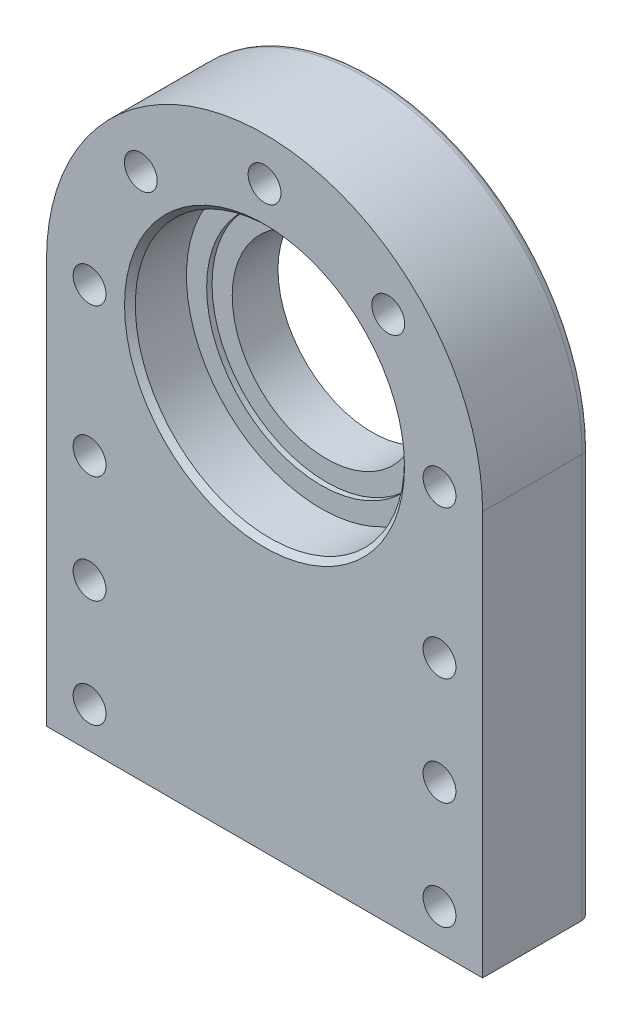
from build123d import *

# Parameters (mm, degrees)
BOSS_EXTRUDE1_DEPTH = 40
SKETCH2_R           = 6.1
CUT_EXTRUDE1_DEPTH  = 40
CIRPATTERN1_COUNT   = 5
CIRPATTERN1_ANGLE   = 180
SKETCH3_R           = 6.1
CUT_EXTRUDE2_DEPTH  = 40
SKETCH4_R           = 50
CUT_EXTRUDE3_DEPTH  = 21
SKETCH5_R           = 42.5
CUT_EXTRUDE4_DEPTH  = 2
SKETCH6_R           = 35
CUT_EXTRUDE5_DEPTH  = 17
CHAMFER1_SIZE       = 2
FILLET1_R           = 3


with BuildPart() as part:
    # Sketch1 → Boss-Extrude1 (new body)
    with BuildSketch(Plane.XY):
        with BuildLine():
            Line((-81, 0), (-81, -150))
            Line((-81, -150), (81, -150))
            Line((81, -150), (81, 0))
            ThreePointArc((81, 0), (0, 81), (-81, 0))
        make_face()
    extrude(amount=BOSS_EXTRUDE1_DEPTH)

    # Sketch2 → Cut-Extrude1 (cut)
    with BuildSketch(Plane.XY.offset(40)):
        with Locations((-65, 0)):
            Circle(SKETCH2_R)
    cut_extrude1 = extrude(amount=-CUT_EXTRUDE1_DEPTH, mode=Mode.SUBTRACT)

    # CirPattern1: Cut-Extrude1 ×5 about axis
    cirpattern1_axis = Axis((0, 0, 0), (0, 0, -1))
    for i in range(1, CIRPATTERN1_COUNT):
        add(cut_extrude1.rotate(cirpattern1_axis, i * CIRPATTERN1_ANGLE / (CIRPATTERN1_COUNT - 1)), mode=Mode.SUBTRACT)

    # Sketch3 → Cut-Extrude2 (cut)
    with BuildSketch(Plane.XY.offset(40)):
        with Locations((-65, -135)):
            Circle(SKETCH3_R)
        with Locations((-65, -95)):
            Circle(SKETCH3_R)
        with Locations((-65, -55)):
            Circle(SKETCH3_R)
    cut_extrude2 = extrude(amount=-CUT_EXTRUDE2_DEPTH, mode=Mode.SUBTRACT)

    # Mirror1: Cut-Extrude2 across plane
    add(cut_extrude2.mirror(Plane(origin=(0, 0, 0), x_dir=(0, 0, 1), z_dir=(1, 0, 0))), mode=Mode.SUBTRACT)

    # Sketch4 → Cut-Extrude3 (cut)
    with BuildSketch(Plane.XY.offset(40)):
        Circle(SKETCH4_R)
    extrude(amount=-CUT_EXTRUDE3_DEPTH, mode=Mode.SUBTRACT)

    # Sketch5 → Cut-Extrude4 (cut)
    with BuildSketch(Plane.XY.offset(19)):
        Circle(SKETCH5_R)
    extrude(amount=-CUT_EXTRUDE4_DEPTH, mode=Mode.SUBTRACT)

    # Sketch6 → Cut-Extrude5 (cut)
    with BuildSketch(Plane.XY.offset(17)):
        Circle(SKETCH6_R)
    extrude(amount=-CUT_EXTRUDE5_DEPTH, mode=Mode.SUBTRACT)

    # Chamfer1
    chamfer1_edges = [part.edges().sort_by_distance(p)[0] for p in [
        (-50, 0, 40),
    ]]
    chamfer(chamfer1_edges, length=CHAMFER1_SIZE)

    # Fillet1
    fillet1_edges = [part.edges().sort_by_distance(p)[0] for p in [
        (81, -75, 0),
        (0, -150, 0),
        (-81, -75, 0),
        (0, 81, 0),
    ]]
    fillet(fillet1_edges, radius=FILLET1_R)


solid = part.part
